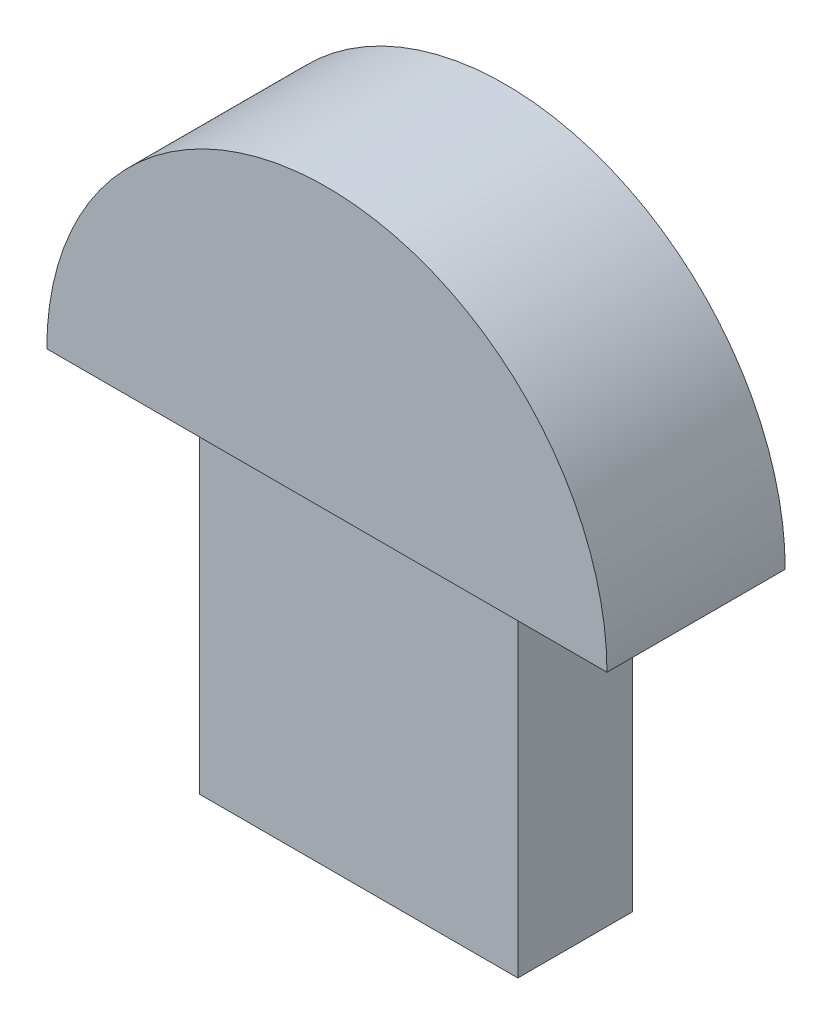
from build123d import *

# Parameters (mm, degrees)
SKETCH1_W           = 12.5
SKETCH1_H           = 4.5
BOSS_EXTRUDE1_DEPTH = 13.4
BOSS_EXTRUDE2_DEPTH = 3.5


with BuildPart() as part:
    # Sketch1 → Boss-Extrude1 (new body)
    with BuildSketch(Plane(origin=(0, 0, 0), x_dir=(1, 0, 0), z_dir=(0, 1, 0))):
        Rectangle(SKETCH1_W, SKETCH1_H)
    extrude(amount=BOSS_EXTRUDE1_DEPTH)

    # Sketch2 → Boss-Extrude2 (add, symmetric)
    with BuildSketch(Plane.XY):
        with BuildLine():
            Line((-11, 13.4), (11, 13.4))
            ThreePointArc((11, 13.4), (0, 24.4), (-11, 13.4))
        make_face()
    extrude(amount=BOSS_EXTRUDE2_DEPTH, both=True)


solid = part.part
